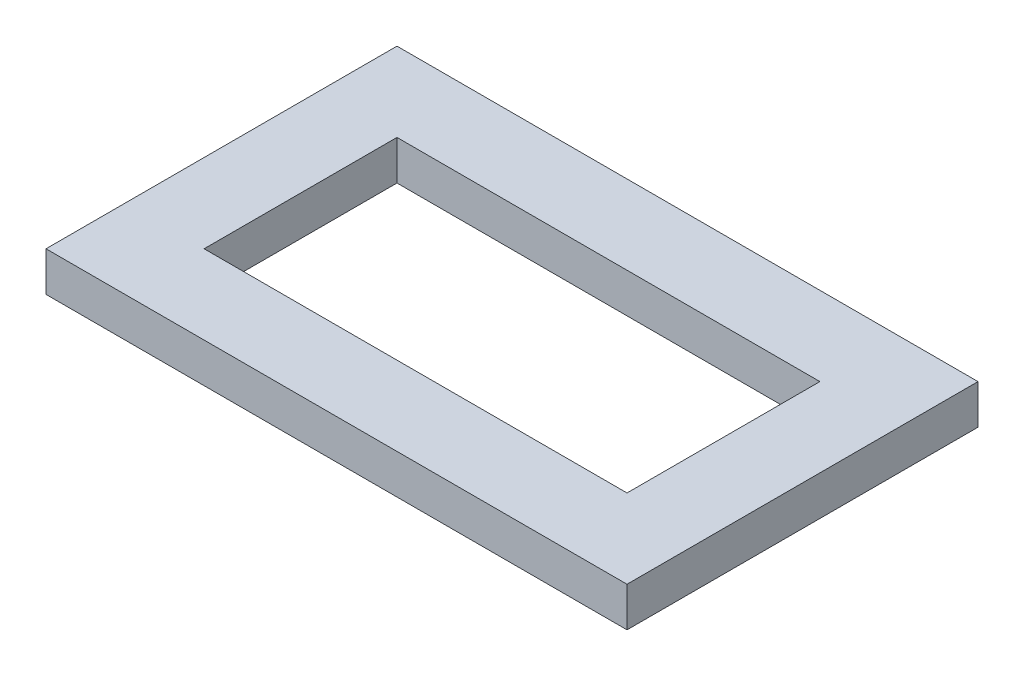
from build123d import *

# Parameters (mm, degrees)
SKETCH1_W           = 36.75
SKETCH1_H           = 22.2
SKETCH1_W_2         = 26.75
SKETCH1_H_2         = 12.2
BOSS_EXTRUDE1_DEPTH = 2.5


with BuildPart() as part:
    # Sketch1 → Boss-Extrude1 (new body)
    with BuildSketch(Plane(origin=(0, 0, 0), x_dir=(1, 0, 0), z_dir=(0, 1, 0))):
        with Locations((13.375, 6.1)):
            Rectangle(SKETCH1_W, SKETCH1_H)
        with Locations((13.375, 6.1)):
            Rectangle(SKETCH1_W_2, SKETCH1_H_2, mode=Mode.SUBTRACT)
    extrude(amount=BOSS_EXTRUDE1_DEPTH)


solid = part.part
